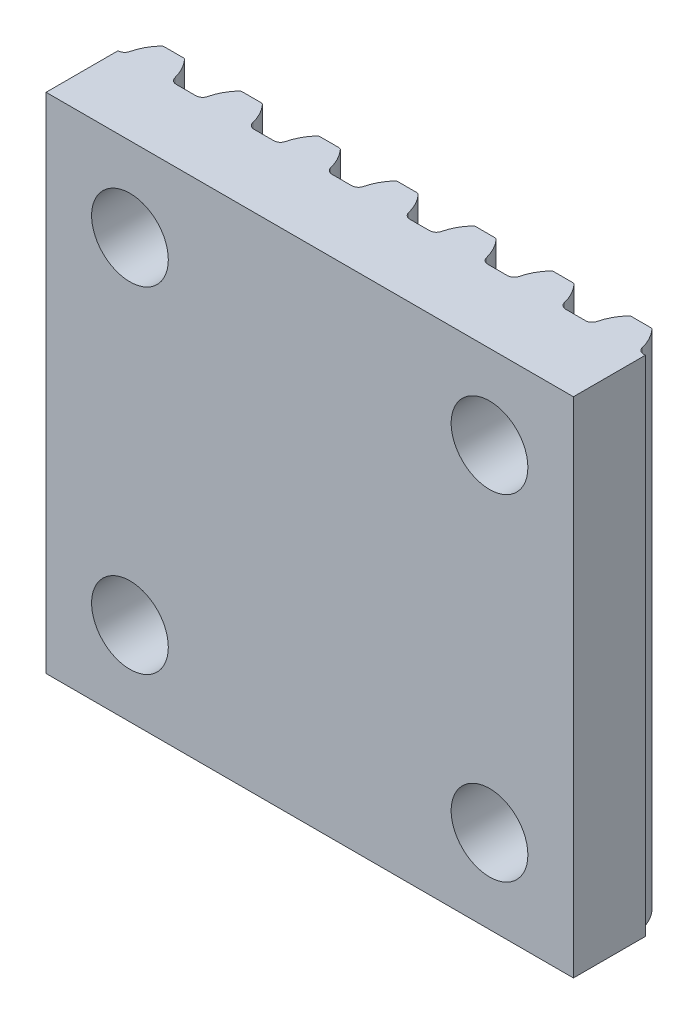
from build123d import *

# Parameters (mm, degrees)
SKETCH_1_W                  = 22
SKETCH_1_H                  = 21
EXTRUDE_1_DEPTH             = 3
EXTRUDE_2_DEPTH             = 21
PATTERN_LINEAR_4_COUNT      = 7
PATTERN_LINEAR_4_PITCH      = 3.25
SKETCH_2_R                  = 1.6
CUT_EXTRUDE_1_DEPTH         = 5.11
PATTERN_LINEAR_1_COUNT      = 2
PATTERN_LINEAR_1_PITCH      = 15
PATTERN_LINEAR_1_COUNT_DIR2 = 2
PATTERN_LINEAR_1_PITCH_DIR2 = 14


with BuildPart() as part:
    # 草圖1 → 填料-伸長1 (new body)
    with BuildSketch(Plane.XY):
        Rectangle(SKETCH_1_W, SKETCH_1_H)
    extrude(amount=EXTRUDE_1_DEPTH)

    # 草圖3 → 填料-伸長2 (add)
    with BuildSketch(Plane.XZ.offset(10.5)):
        with BuildLine():
            Line((-10.171794795, -1.11), (-9.396484538, -1.11))
            ThreePointArc((-9.396484538, -1.11), (-9.335113223, -1.096870602), (-9.284485486, -1.059780822))
            ThreePointArc((-9.284485486, -1.059780822), (-9.010457293, -0.664005968), (-8.840315206, -0.213694013))
            ThreePointArc((-8.840315206, -0.213694013), (-8.741245116, -0.059811812), (-8.568279333, 0))
            Line((-8.568279333, 0), (-11, 0))
            ThreePointArc((-11, 0), (-10.827034218, -0.059811812), (-10.727964127, -0.213694013))
            ThreePointArc((-10.727964127, -0.213694013), (-10.55782204, -0.664005968), (-10.283793847, -1.059780822))
            ThreePointArc((-10.283793847, -1.059780822), (-10.233166111, -1.096870602), (-10.171794795, -1.11))
        make_face()
    extrude_2 = extrude(amount=-EXTRUDE_2_DEPTH)

    # 直線複製排列4: 填料-伸長2 ×7
    with Locations(*[(i * PATTERN_LINEAR_4_PITCH, 0, 0) for i in range(1, PATTERN_LINEAR_4_COUNT)]):
        add(extrude_2)

    # 草圖2 → 除料-伸長1 (cut, through all)
    with BuildSketch(Plane.XY.offset(3)):
        with Locations((-7.5, 7)):
            Circle(SKETCH_2_R)
    cut_extrude_1 = extrude(amount=-CUT_EXTRUDE_1_DEPTH, mode=Mode.SUBTRACT)

    # 直線複製排列1: Cut-Extrude 1 2 × 2
    with Locations(*[(i * PATTERN_LINEAR_1_PITCH, -j * PATTERN_LINEAR_1_PITCH_DIR2, 0) for i in range(PATTERN_LINEAR_1_COUNT) for j in range(PATTERN_LINEAR_1_COUNT_DIR2) if (i, j) != (0, 0)]):
        add(cut_extrude_1, mode=Mode.SUBTRACT)


solid = part.part
